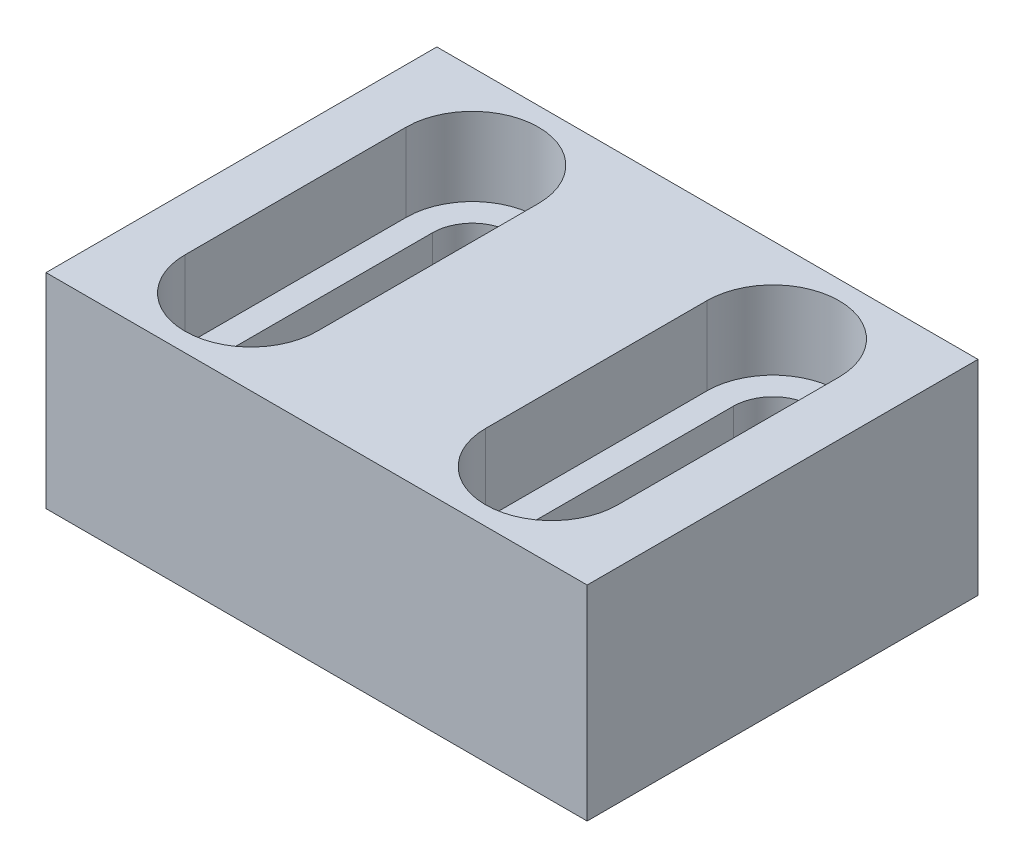
from build123d import *

# Parameters (mm, degrees)
SKETCH1_W             = 45
SKETCH1_H             = 32.5
BOSS_EXTRUDE1_DEPTH   = 17
CUT_EXTRUDE1_DEPTH    = 6.5
M3_TAPPED_HOLE1_D     = 2.5
M3_TAPPED_HOLE1_DEPTH = 10
M3_TAPPED_HOLE1_TIP   = 0.751075774


with BuildPart() as part:
    # Sketch1 → Boss-Extrude1 (new body)
    with BuildSketch(Plane(origin=(0, 0, 0), x_dir=(1, 0, 0), z_dir=(0, 1, 0))):
        Rectangle(SKETCH1_W, SKETCH1_H)
        with BuildLine():
            Line((-15.8, -9.2), (-15.8, 9.2))
            ThreePointArc((-15.8, 9.2), (-12.5, 12.5), (-9.2, 9.2))
            Line((-9.2, 9.2), (-9.2, -9.2))
            ThreePointArc((-9.2, -9.2), (-12.5, -12.5), (-15.8, -9.2))
        make_face(mode=Mode.SUBTRACT)
        with BuildLine():
            Line((9.2, -9.2), (9.2, 9.2))
            ThreePointArc((9.2, 9.2), (12.5, 12.5), (15.8, 9.2))
            Line((15.8, 9.2), (15.8, -9.2))
            ThreePointArc((15.8, -9.2), (12.5, -12.5), (9.2, -9.2))
        make_face(mode=Mode.SUBTRACT)
    extrude(amount=BOSS_EXTRUDE1_DEPTH)

    # Sketch2 → Cut-Extrude1 (cut)
    with BuildSketch(Plane(origin=(0, 17, 0), x_dir=(1, 0, 0), z_dir=(0, 1, 0))):
        with BuildLine():
            Line((18, -9.2), (18, 9.2))
            ThreePointArc((18, 9.2), (12.5, 14.7), (7, 9.2))
            Line((7, 9.2), (7, -9.2))
            ThreePointArc((7, -9.2), (12.5, -14.7), (18, -9.2))
        make_face()
        with BuildLine():
            Line((-7, -9.2), (-7, 9.2))
            ThreePointArc((-7, 9.2), (-12.5, 14.7), (-18, 9.2))
            Line((-18, 9.2), (-18, -9.2))
            ThreePointArc((-18, -9.2), (-12.5, -14.7), (-7, -9.2))
        make_face()
    extrude(amount=-CUT_EXTRUDE1_DEPTH, mode=Mode.SUBTRACT)

    # M3 Tapped Hole1
    with Locations(Plane(origin=(0, 0, -16.25), x_dir=(-1, 0, 0), z_dir=(0, 0, -1))):
        with Locations((-18.5, 5), (0, 12), (18.5, 5)):
            Hole(M3_TAPPED_HOLE1_D / 2, depth=M3_TAPPED_HOLE1_DEPTH)
            with Locations((0, 0, -(M3_TAPPED_HOLE1_DEPTH + M3_TAPPED_HOLE1_TIP / 2))):  # 118° drill point
                Cone(0, M3_TAPPED_HOLE1_D / 2, M3_TAPPED_HOLE1_TIP, mode=Mode.SUBTRACT)


solid = part.part
